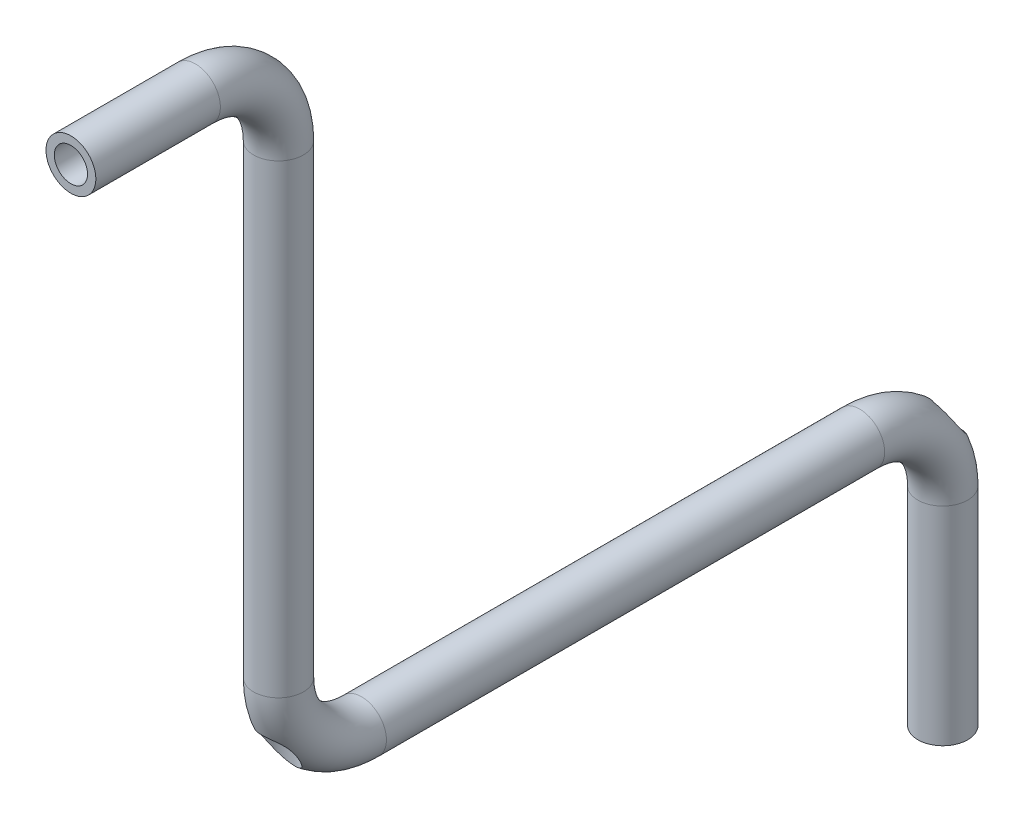
from build123d import *

# Parameters (mm, degrees)
SWEEP_THIN2_PROFILE_R   = 30
SWEEP_THIN2_PROFILE_R_2 = 20
CUT_EXTRUDE1_DEPTH      = 86
CUT_EXTRUDE1_DEPTH_BACK = 10
SKETCH25_R              = 20
CUT_EXTRUDE2_DEPTH      = 312
CUT_EXTRUDE2_DEPTH_BACK = 10
SKETCH28_R              = 20
SKETCH29_R              = 20.008995332
CUT_EXTRUDE4_DEPTH      = 64


with BuildPart() as part:
    # Sweep-Thin2: sweep along a path in Sketch1
    with BuildLine(Plane(origin=(0, 0, 0), x_dir=(0, 0, -1), z_dir=(1, 0, 0))) as sweep_thin2_path:
        Line((800, -350), (800, -100))
        ThreePointArc((800, -100), (770.710678119, -29.289321881), (700, 0))
        Line((700, 0), (100, 0))
        ThreePointArc((100, 0), (29.289321881, 29.289321881), (0, 100))
        Line((0, 100), (0, 660))
        ThreePointArc((0, 660), (-29.289321881, 730.710678119), (-100, 760))
        Line((-100, 760), (-250, 760))
    # Sweep-Thin2 profile (on start of the path) → Sweep-Thin2 (sweep)
    with BuildSketch(Plane(origin=(0, -350, -800), x_dir=(0, 0, 1), z_dir=(0, 1, 0))):
        Circle(SWEEP_THIN2_PROFILE_R)
        Circle(SWEEP_THIN2_PROFILE_R_2, mode=Mode.SUBTRACT)
    sweep(path=sweep_thin2_path.line)

    # Sketch25 → Cut-Extrude1 (cut, two sides: drawn at the far end of the back side and taken through both)
    with BuildSketch(Plane(origin=(0, 0, 0), x_dir=(1, 0, 0), z_dir=(0, 1, 0)).offset(-CUT_EXTRUDE1_DEPTH_BACK)):
        Circle(SKETCH25_R)
    extrude(amount=CUT_EXTRUDE1_DEPTH + CUT_EXTRUDE1_DEPTH_BACK, mode=Mode.SUBTRACT)

    # Sketch28 → Cut-Extrude2 (cut, two sides: drawn at the far end of the back side and taken through both)
    with BuildSketch(Plane.XY.offset(-330).offset(-CUT_EXTRUDE2_DEPTH_BACK)):
        with Locations((0, 370)):
            Circle(SKETCH28_R)
    extrude(amount=CUT_EXTRUDE2_DEPTH + CUT_EXTRUDE2_DEPTH_BACK, mode=Mode.SUBTRACT)

    # Sketch29 → Cut-Extrude4 (cut)
    with BuildSketch(Plane(origin=(0, 0, 0), x_dir=(1, 0, 0), z_dir=(0, 1, 0))):
        with Locations((0, 800)):
            Circle(SKETCH29_R)
    extrude(amount=-CUT_EXTRUDE4_DEPTH, mode=Mode.SUBTRACT)


solid = part.part
